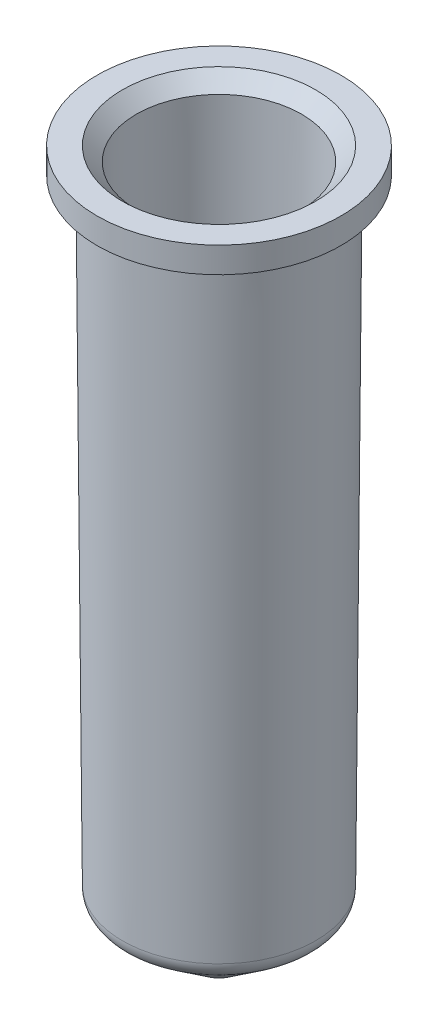
from build123d import *


with BuildPart() as part:
    # Sketch1 → Revolve1 (revolve)
    with BuildSketch(Plane.XY):
        with BuildLine():
            Line((1.197299905, -3.457984677), (4.752406997, -0.801010758))
            ThreePointArc((4.752406997, -0.801010758), (5.046117858, -0.451322699), (5.153728827, -0.007512281))
            Line((5.153728827, -0.007512281), (5.4, 32.774036839))
            Line((5.4, 32.774036839), (6.504629528, 32.774036839))
            Line((6.504629528, 32.774036839), (6.504629528, 34.144036839))
            Line((6.504629528, 34.144036839), (5.154629528, 34.144036839))
            Line((5.154629528, 34.144036839), (4.404629528, 33.394036839))
            Line((4.404629528, 33.394036839), (4.153757045, 0))
            Line((4.153757045, 0), (0.598649953, -2.656973919))
            ThreePointArc((0.598649953, -2.656973919), (0.31542768, -2.80491278), (0, -2.855963161))
            Line((0, -2.855963161), (0, -3.855963161))
            ThreePointArc((0, -3.855963161), (0.630855359, -3.753862399), (1.197299905, -3.457984677))
        make_face()
    revolve(axis=Axis((0, 0, 0), (0, 1, 0)))


solid = part.part
